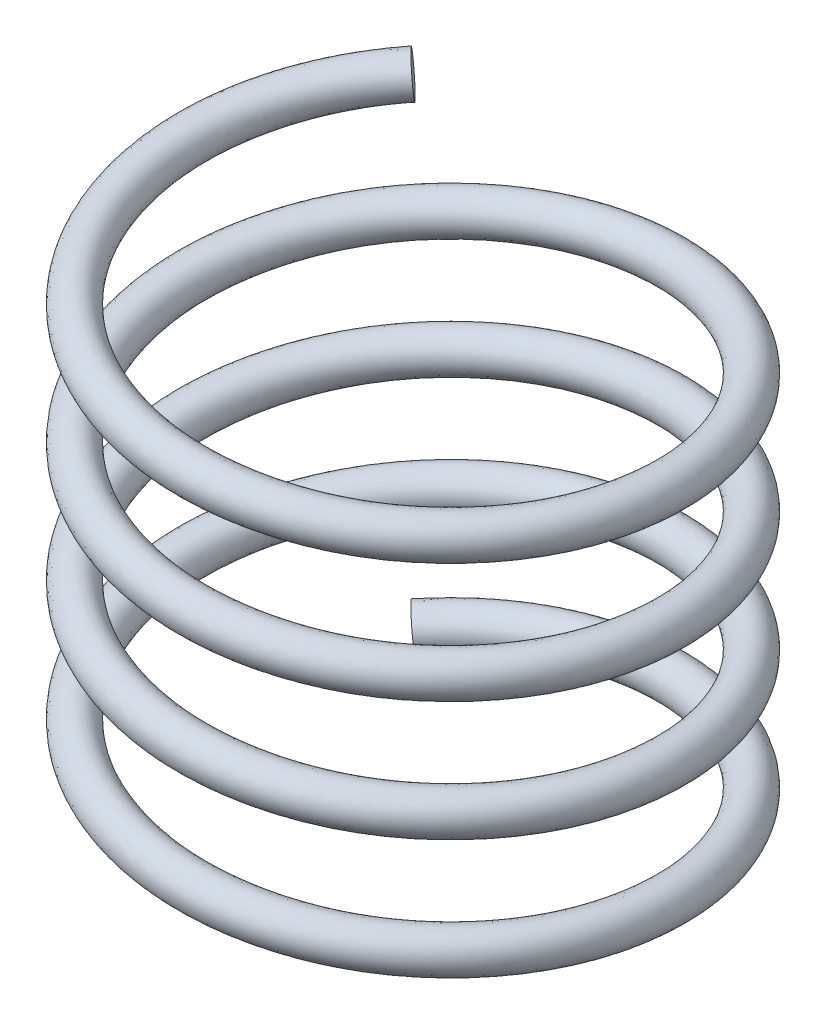
from build123d import *

# Parameters (mm, degrees)
SWEEP_1_PITCH       = 3
SWEEP_1_HEIGHT      = 12
SWEEP_1_RADIUS      = 6
SWEEP_1_START_ANGLE = -135
SWEEP_1_PROFILE_R   = 0.5


with BuildPart() as part:
    # 스윕1: sweep along a helix
    with BuildLine() as sweep_1_path:
        add(Helix(SWEEP_1_PITCH, SWEEP_1_HEIGHT, SWEEP_1_RADIUS, center=(0, 0, 0), direction=(0, 1, 0), lefthand=True, mode=Mode.PRIVATE).rotate(Axis((0, 0, 0), (0, 1, 0)), SWEEP_1_START_ANGLE))
    # 스윕1 profile (on start of the path) → 스윕1 (sweep)
    with BuildSketch(Plane(origin=(-4.242640687, 0, -4.242640687), x_dir=(-0.707106781, 0, -0.707106781), z_dir=(0.704878456, 0.079326697, -0.704878456))):
        Circle(SWEEP_1_PROFILE_R)
    sweep(path=sweep_1_path.line, is_frenet=True)


solid = part.part
